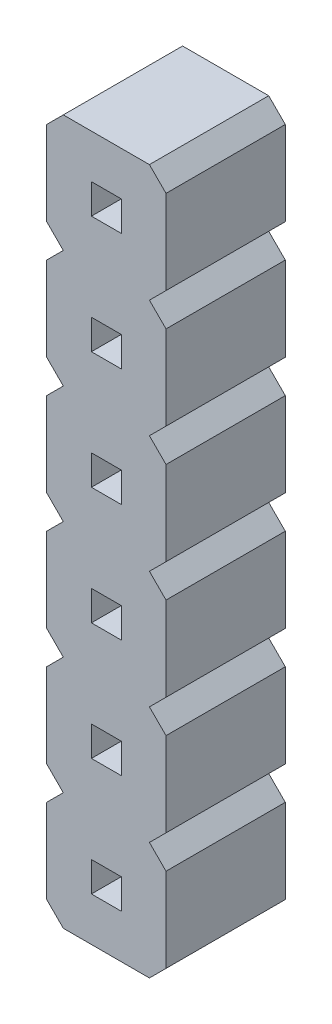
from build123d import *

# Parameters (mm, degrees)
PIN_BODY_W          = 0.636
PIN_BODY_H          = 0.636
BOSS_EXTRUDE1_DEPTH = 2.54


with BuildPart() as part:
    # pin_body → Boss-Extrude1 (new body)
    with BuildSketch(Plane.XY):
        Polygon((0, 2.146446609), (0, 0.353553391), (0.353553391, 0), (0, -0.353553391), (0, -2.146446609), (0.353553391, -2.5), (2.187446609, -2.5), (2.541, -2.146446609), (2.541, -0.353553391), (2.187446609, 0), (2.541, 0.353553391), (2.541, 2.146446609), (2.187446609, 2.5), (2.541, 2.853553391), (2.541, 4.646446609), (2.187446609, 5), (2.541, 5.353553391), (2.541, 7.146446609), (2.187446609, 7.5), (2.541, 7.853553391), (2.541, 9.646446609), (2.187446609, 10), (2.541, 10.353553391), (2.541, 12.146446609), (2.187446609, 12.5), (0.353553391, 12.5), (0, 12.146446609), (0, 10.353553391), (0.353553391, 10), (0, 9.646446609), (0, 7.853553391), (0.353553391, 7.5), (0, 7.146446609), (0, 5.353553391), (0.353553391, 5), (0, 4.646446609), (0, 2.853553391), (0.353553391, 2.5), align=None)
        with Locations((1.2705, -1.25)):
            Rectangle(PIN_BODY_W, PIN_BODY_H, mode=Mode.SUBTRACT)
        with Locations((1.2705, 1.25)):
            Rectangle(PIN_BODY_W, PIN_BODY_H, mode=Mode.SUBTRACT)
        with Locations((1.2705, 3.75)):
            Rectangle(PIN_BODY_W, PIN_BODY_H, mode=Mode.SUBTRACT)
        with Locations((1.2705, 6.25)):
            Rectangle(PIN_BODY_W, PIN_BODY_H, mode=Mode.SUBTRACT)
        with Locations((1.2705, 8.75)):
            Rectangle(PIN_BODY_W, PIN_BODY_H, mode=Mode.SUBTRACT)
        with Locations((1.2705, 11.25)):
            Rectangle(PIN_BODY_W, PIN_BODY_H, mode=Mode.SUBTRACT)
    extrude(amount=BOSS_EXTRUDE1_DEPTH)


solid = part.part
